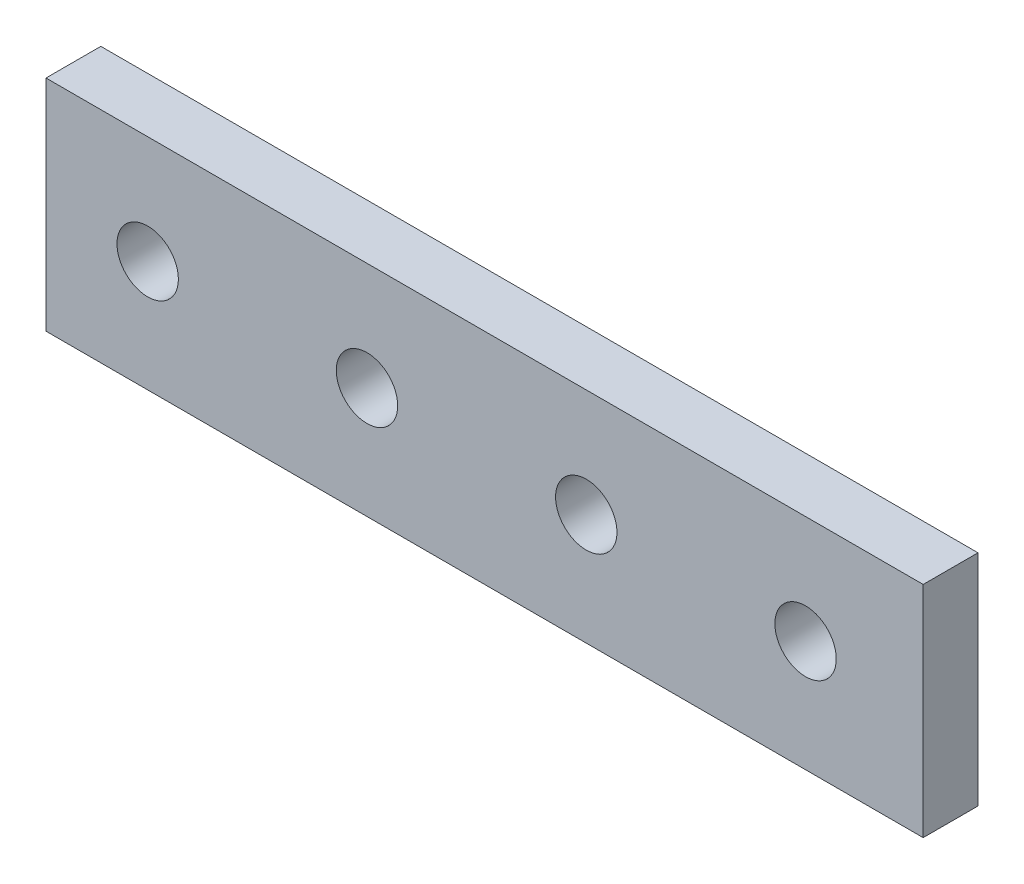
from build123d import *

# Parameters (mm, degrees)
SKETCH1_W           = 101.6
SKETCH1_H           = 25.4
BOSS_EXTRUDE1_DEPTH = 6.35
SKETCH2_R           = 3.556
CUT_EXTRUDE1_DEPTH  = 7.35


with BuildPart() as part:
    # Sketch1 → Boss-Extrude1 (new body)
    with BuildSketch(Plane.XY):
        with Locations((-16.374380161, -9.255956692)):
            Rectangle(SKETCH1_W, SKETCH1_H)
    extrude(amount=BOSS_EXTRUDE1_DEPTH)

    # Sketch2 → Cut-Extrude1 (cut, through all)
    with BuildSketch(Plane.XY.offset(6.35)):
        with Locations((-55.39796797, -9.067376)):
            Circle(SKETCH2_R)
        with Locations((-29.99796797, -9.067376)):
            Circle(SKETCH2_R)
        with Locations((-4.59796797, -9.067376)):
            Circle(SKETCH2_R)
        with Locations((20.80203203, -9.067376)):
            Circle(SKETCH2_R)
    extrude(amount=-CUT_EXTRUDE1_DEPTH, mode=Mode.SUBTRACT)


solid = part.part
